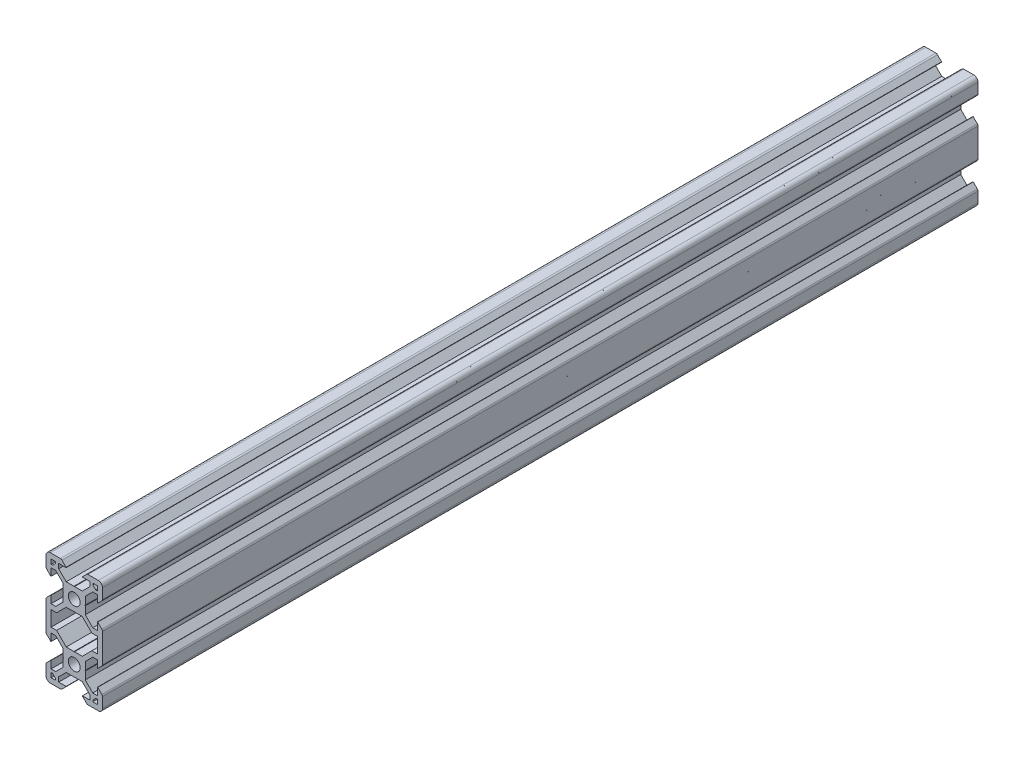
from build123d import *

# Parameters (mm, degrees)
SKETCH2_R           = 2.1
BOSS_EXTRUDE1_DEPTH = 310


with BuildPart() as part:
    # Sketch2 → Boss-Extrude1 (new body)
    with BuildSketch(Plane.XY):
        with BuildLine():
            Line((-0.1, 3.9), (0, 3.8))
            Line((0, 3.8), (0.1, 3.9))
            Line((0.1, 3.9), (2.840365134, 3.9))
            Line((2.840365134, 3.9), (5.5, 6.558825842))
            Line((5.5, 6.558825842), (5.5, 8.197505675))
            Line((5.5, 8.197505675), (2.89, 8.197505675))
            Line((2.89, 8.197505675), (2.89, 8.307505675))
            Line((2.89, 8.307505675), (4.348614357, 9.766120032))
            ThreePointArc((4.348614357, 9.766120032), (4.604908803, 9.937370505), (4.907228714, 9.997505675))
            Line((4.907228714, 9.997505675), (8.5, 9.997505675))
            ThreePointArc((8.5, 9.997505675), (9.560660172, 9.558165846), (10, 8.497505675))
            Line((10, 8.497505675), (10, 4.904734389))
            ThreePointArc((10, 4.904734389), (9.939864831, 4.602414477), (9.768614357, 4.346120032))
            Line((9.768614357, 4.346120032), (8.31, 2.887505675))
            Line((8.31, 2.887505675), (8.2, 2.887505675))
            Line((8.2, 2.887505675), (8.2, 5.497505675))
            Line((8.2, 5.497505675), (6.56, 5.497505675))
            Line((6.56, 5.497505675), (3.9, 2.83831481))
            Line((3.9, 2.83831481), (3.9, 0.1))
            Line((3.9, 0.1), (3.8, 0))
            Line((3.8, 0), (3.9, -0.1))
            Line((3.9, -0.1), (3.9, -2.84))
            Line((3.9, -2.84), (6.56, -5.5))
            Line((6.56, -5.5), (8.2, -5.5))
            Line((8.2, -5.5), (8.2, -2.89))
            Line((8.2, -2.89), (8.31, -2.89))
            Line((8.31, -2.89), (9.765685425, -4.345685425))
            ThreePointArc((9.765685425, -4.345685425), (9.939103626, -4.605224104), (10, -4.91137085))
            Line((10, -4.91137085), (10, -15.08862915))
            ThreePointArc((10, -15.08862915), (9.939103626, -15.394775896), (9.765685425, -15.654314575))
            Line((9.765685425, -15.654314575), (8.31, -17.11))
            Line((8.31, -17.11), (8.2, -17.11))
            Line((8.2, -17.11), (8.2, -14.5))
            Line((8.2, -14.5), (6.56, -14.5))
            Line((6.56, -14.5), (3.9, -17.16))
            Line((3.9, -17.16), (3.9, -19.9))
            Line((3.9, -19.9), (3.8, -20))
            Line((3.8, -20), (3.9, -20.1))
            Line((3.9, -20.1), (3.9, -22.83831481))
            Line((3.9, -22.83831481), (6.56, -25.497505675))
            Line((6.56, -25.497505675), (8.2, -25.497505675))
            Line((8.2, -25.497505675), (8.2, -22.887505675))
            Line((8.2, -22.887505675), (8.31, -22.887505675))
            Line((8.31, -22.887505675), (9.768614357, -24.346120032))
            ThreePointArc((9.768614357, -24.346120032), (9.939864831, -24.602414477), (10, -24.904734389))
            Line((10, -24.904734389), (10, -28.497505675))
            ThreePointArc((10, -28.497505675), (9.560660172, -29.558165846), (8.5, -29.997505675))
            Line((8.5, -29.997505675), (4.907228714, -29.997505675))
            ThreePointArc((4.907228714, -29.997505675), (4.604908803, -29.937370505), (4.348614357, -29.766120032))
            Line((4.348614357, -29.766120032), (2.89, -28.307505675))
            Line((2.89, -28.307505675), (2.89, -28.197505675))
            Line((2.89, -28.197505675), (5.5, -28.197505675))
            Line((5.5, -28.197505675), (5.5, -26.558825842))
            Line((5.5, -26.558825842), (2.840365134, -23.9))
            Line((2.840365134, -23.9), (0.1, -23.9))
            Line((0.1, -23.9), (0, -23.8))
            Line((0, -23.8), (-0.1, -23.9))
            Line((-0.1, -23.9), (-2.840365134, -23.9))
            Line((-2.840365134, -23.9), (-5.5, -26.558825842))
            Line((-5.5, -26.558825842), (-5.5, -28.197505675))
            Line((-5.5, -28.197505675), (-2.89, -28.197505675))
            Line((-2.89, -28.197505675), (-2.89, -28.307505675))
            Line((-2.89, -28.307505675), (-4.348614357, -29.766120032))
            ThreePointArc((-4.348614357, -29.766120032), (-4.604908803, -29.937370505), (-4.907228714, -29.997505675))
            Line((-4.907228714, -29.997505675), (-8.5, -29.997505675))
            ThreePointArc((-8.5, -29.997505675), (-9.560660172, -29.558165846), (-10, -28.497505675))
            Line((-10, -28.497505675), (-10, -24.904734389))
            ThreePointArc((-10, -24.904734389), (-9.939864831, -24.602414477), (-9.768614357, -24.346120032))
            Line((-9.768614357, -24.346120032), (-8.31, -22.887505675))
            Line((-8.31, -22.887505675), (-8.2, -22.887505675))
            Line((-8.2, -22.887505675), (-8.2, -25.497505675))
            Line((-8.2, -25.497505675), (-6.56, -25.497505675))
            Line((-6.56, -25.497505675), (-3.9, -22.83831481))
            Line((-3.9, -22.83831481), (-3.9, -20.1))
            Line((-3.9, -20.1), (-3.8, -20))
            Line((-3.8, -20), (-3.9, -19.9))
            Line((-3.9, -19.9), (-3.9, -17.16))
            Line((-3.9, -17.16), (-6.56, -14.5))
            Line((-6.56, -14.5), (-8.2, -14.5))
            Line((-8.2, -14.5), (-8.2, -17.11))
            Line((-8.2, -17.11), (-8.31, -17.11))
            Line((-8.31, -17.11), (-9.765685425, -15.654314575))
            ThreePointArc((-9.765685425, -15.654314575), (-9.939103626, -15.394775896), (-10, -15.08862915))
            Line((-10, -15.08862915), (-10, -4.91137085))
            ThreePointArc((-10, -4.91137085), (-9.939103626, -4.605224104), (-9.765685425, -4.345685425))
            Line((-9.765685425, -4.345685425), (-8.31, -2.89))
            Line((-8.31, -2.89), (-8.2, -2.89))
            Line((-8.2, -2.89), (-8.2, -5.5))
            Line((-8.2, -5.5), (-6.56, -5.5))
            Line((-6.56, -5.5), (-3.9, -2.84))
            Line((-3.9, -2.84), (-3.9, -0.1))
            Line((-3.9, -0.1), (-3.8, 0))
            Line((-3.8, 0), (-3.9, 0.1))
            Line((-3.9, 0.1), (-3.9, 2.83831481))
            Line((-3.9, 2.83831481), (-6.56, 5.497505675))
            Line((-6.56, 5.497505675), (-8.2, 5.497505675))
            Line((-8.2, 5.497505675), (-8.2, 2.887505675))
            Line((-8.2, 2.887505675), (-8.31, 2.887505675))
            Line((-8.31, 2.887505675), (-9.768614357, 4.346120032))
            ThreePointArc((-9.768614357, 4.346120032), (-9.939864831, 4.602414477), (-10, 4.904734389))
            Line((-10, 4.904734389), (-10, 8.497505675))
            ThreePointArc((-10, 8.497505675), (-9.560660172, 9.558165846), (-8.5, 9.997505675))
            Line((-8.5, 9.997505675), (-4.907228714, 9.997505675))
            ThreePointArc((-4.907228714, 9.997505675), (-4.604908803, 9.937370505), (-4.348614357, 9.766120032))
            Line((-4.348614357, 9.766120032), (-2.89, 8.307505675))
            Line((-2.89, 8.307505675), (-2.89, 8.197505675))
            Line((-2.89, 8.197505675), (-5.5, 8.197505675))
            Line((-5.5, 8.197505675), (-5.5, 6.558825842))
            Line((-5.5, 6.558825842), (-2.840365134, 3.9))
            Line((-2.840365134, 3.9), (-0.1, 3.9))
        make_face()
        Circle(SKETCH2_R, mode=Mode.SUBTRACT)
        with Locations((0, -20)):
            Circle(SKETCH2_R, mode=Mode.SUBTRACT)
        Polygon((-7.66, 6.567505675), (-6.57, 7.657505675), (-6.57, 8.197505675), (-8.2, 8.197505675), (-8.2, 6.567505675), align=None, mode=Mode.SUBTRACT)
        Polygon((-0.1, -3.9), (0, -3.8), (0.1, -3.9), (2.840365134, -3.9), (6.24, -7.299634866), (8.2, -7.299634866), (8.2, -12.700365134), (6.24, -12.700365134), (2.840365134, -16.1), (0.1, -16.1), (0, -16.2), (-0.1, -16.1), (-2.840365134, -16.1), (-6.24, -12.700365134), (-8.2, -12.700365134), (-8.2, -7.299634866), (-6.24, -7.299634866), (-2.840365134, -3.9), align=None, mode=Mode.SUBTRACT)
        Polygon((8.2, 6.567505675), (7.66, 6.567505675), (6.57, 7.657505675), (6.57, 8.197505675), (8.2, 8.197505675), align=None, mode=Mode.SUBTRACT)
        Polygon((7.66, -26.567505675), (6.57, -27.657505675), (6.57, -28.197505675), (8.2, -28.197505675), (8.2, -26.567505675), align=None, mode=Mode.SUBTRACT)
        Polygon((-8.2, -26.567505675), (-7.66, -26.567505675), (-6.57, -27.657505675), (-6.57, -28.197505675), (-8.2, -28.197505675), align=None, mode=Mode.SUBTRACT)
    extrude(amount=-BOSS_EXTRUDE1_DEPTH)


solid = part.part
